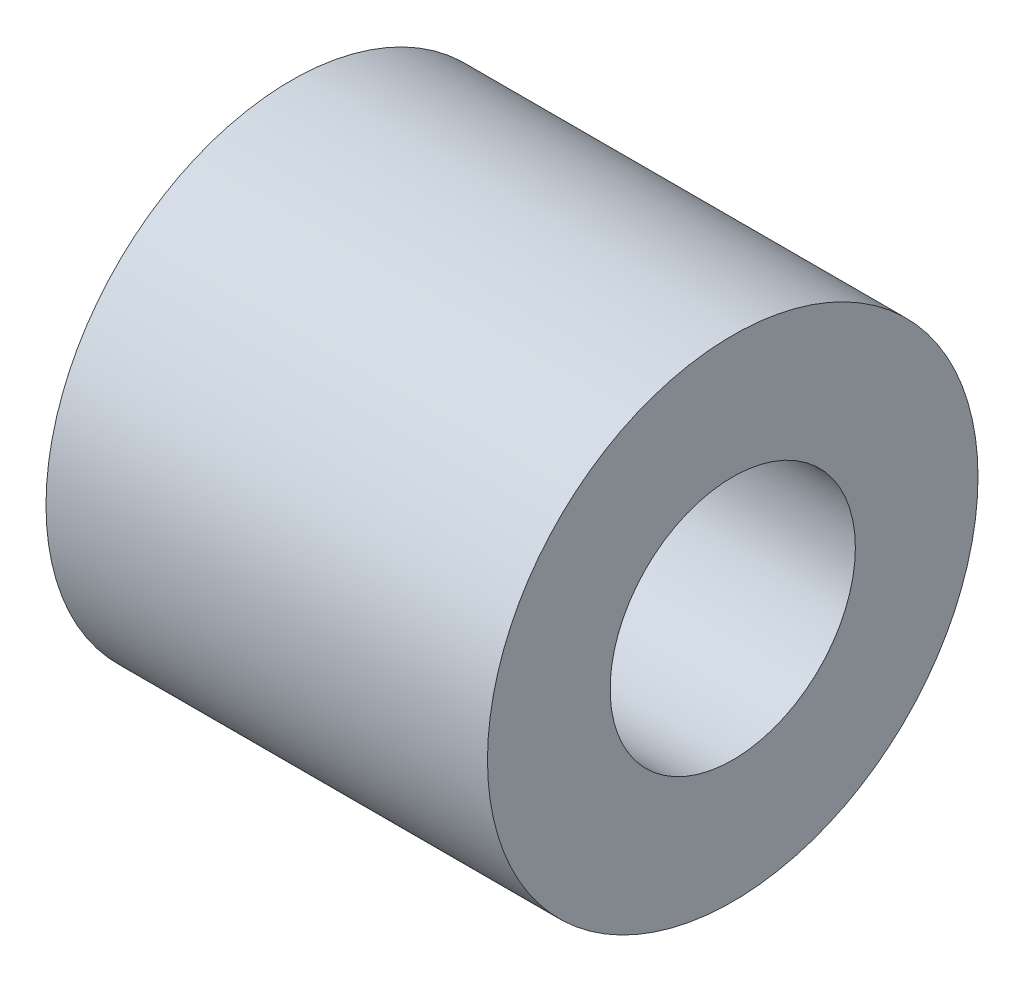
from build123d import *

# Parameters (mm, degrees)
SKETCH1_R           = 5
SKETCH1_R_2         = 2.5
BOSS_EXTRUDE1_DEPTH = 9


with BuildPart() as part:
    # Sketch1 → Boss-Extrude1 (new body)
    with BuildSketch(Plane(origin=(0, 0, 0), x_dir=(0, 0, -1), z_dir=(1, 0, 0))):
        Circle(SKETCH1_R)
        Circle(SKETCH1_R_2, mode=Mode.SUBTRACT)
    extrude(amount=BOSS_EXTRUDE1_DEPTH)


solid = part.part
